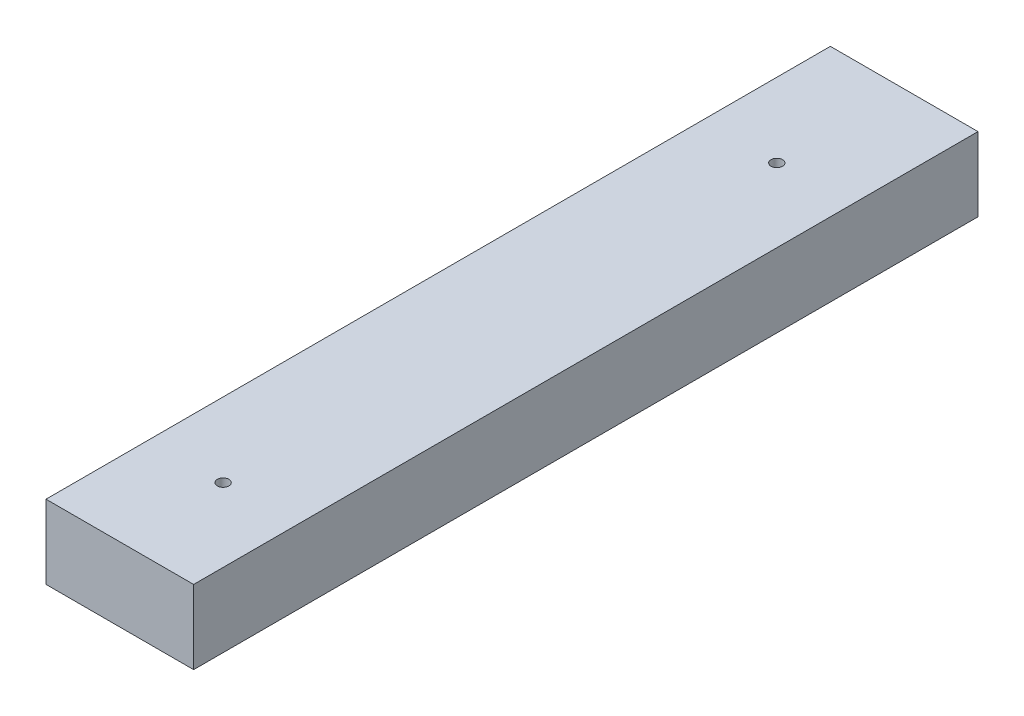
from build123d import *

# Parameters (mm, degrees)
SKETCH1_W           = 101.6
SKETCH1_H           = 50.8
BOSS_EXTRUDE1_DEPTH = 539.75
SKETCH2_R           = 3.96875
CUT_EXTRUDE1_DEPTH  = 51.8


with BuildPart() as part:
    # Sketch1 → Boss-Extrude1 (new body)
    with BuildSketch(Plane.XY):
        with Locations((-50.8, 25.4)):
            Rectangle(SKETCH1_W, SKETCH1_H)
    extrude(amount=BOSS_EXTRUDE1_DEPTH)

    # Sketch2 → Cut-Extrude1 (cut, through all)
    with BuildSketch(Plane(origin=(0, 50.8, 0), x_dir=(1, 0, 0), z_dir=(0, 1, 0))):
        with Locations((-50.532279032, -87.935910633)):
            Circle(SKETCH2_R)
        with Locations((-50.532279032, -468.935910633)):
            Circle(SKETCH2_R)
    extrude(amount=-CUT_EXTRUDE1_DEPTH, mode=Mode.SUBTRACT)


solid = part.part
